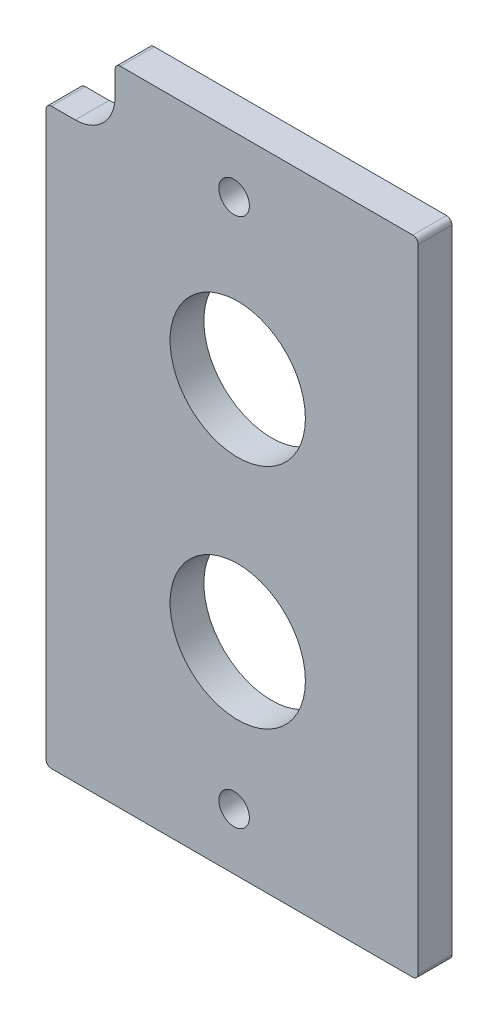
from build123d import *

# Parameters (mm, degrees)
BOSS_EXTRUDE1_DEPTH         = 4.7625
F_6_CLEARANCE_HOLE1_D       = 4.3053
F_3_4_0_75_DIAMETER_HOLE1_D = 19.05


with BuildPart() as part:
    # Sketch1 → Boss-Extrude1 (new body)
    with BuildSketch(Plane.XY):
        with BuildLine():
            Line((-50.8, 124.587), (-54.1655, 124.587))
            ThreePointArc((-54.1655, 124.587), (-54.704315367, 124.363815367), (-54.9275, 123.825))
            Line((-54.9275, 123.825), (-54.9275, 44.577))
            ThreePointArc((-54.9275, 44.577), (-54.704315367, 44.038184633), (-54.1655, 43.815))
            Line((-54.1655, 43.815), (-3.302, 43.815))
            ThreePointArc((-3.302, 43.815), (-2.763184633, 44.038184633), (-2.54, 44.577))
            Line((-2.54, 44.577), (-2.54, 133.5405))
            ThreePointArc((-2.54, 133.5405), (-2.763184633, 134.079315367), (-3.302, 134.3025))
            Line((-3.302, 134.3025), (-44.45, 134.3025))
            ThreePointArc((-44.45, 134.3025), (-44.988815367, 134.079315367), (-45.212, 133.5405))
            Line((-45.212, 133.5405), (-45.212, 130.175))
            ThreePointArc((-45.212, 130.175), (-46.848687307, 126.223687307), (-50.8, 124.587))
        make_face()
    extrude(amount=BOSS_EXTRUDE1_DEPTH)

    # #6 Clearance Hole1 (through all)
    with Locations(Plane.XY.offset(4.7625)):
        with Locations((-28.448, 126.365), (-28.448, 51.7525)):
            Hole(F_6_CLEARANCE_HOLE1_D / 2)

    # 3/4 (0.75) Diameter Hole1 (through all)
    with Locations(Plane.XY.offset(4.7625)):
        with Locations((-27.94, 72.39), (-27.94, 104.394)):
            Hole(F_3_4_0_75_DIAMETER_HOLE1_D / 2)


solid = part.part
